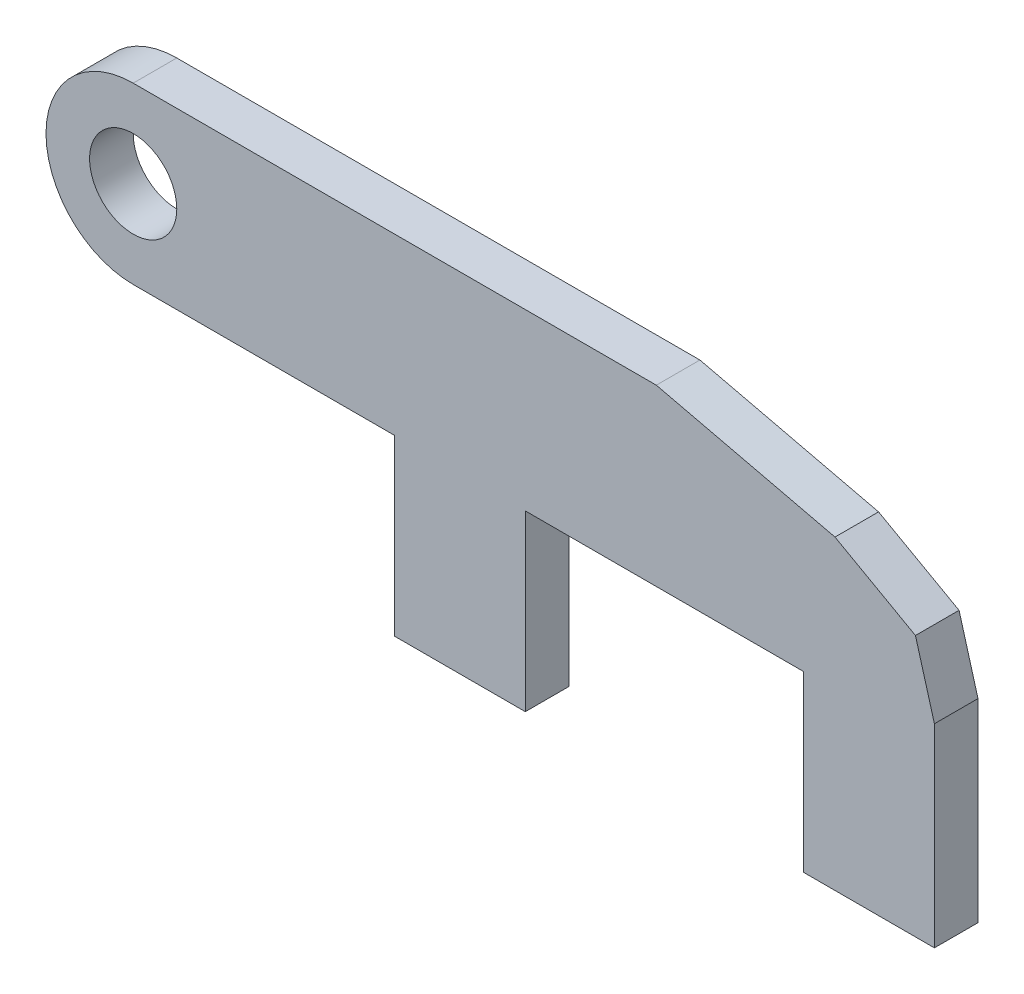
from build123d import *

# Parameters (mm, degrees)
SKETCH1_R           = 5
BOSS_EXTRUDE1_DEPTH = 5


with BuildPart() as part:
    # Sketch1 → Boss-Extrude1 (new body)
    with BuildSketch(Plane.XY):
        with BuildLine():
            Line((0, 20), (60, 20))
            Line((60, 20), (80.493425393, 15.160264355))
            Line((80.493425393, 15.160264355), (89.723935177, 10))
            Line((89.723935177, 10), (91.89696936, 2.317012659))
            Line((91.89696936, 2.317012659), (91.89696936, -19.946286041))
            Line((91.89696936, -19.946286041), (76.89696936, -19.946286041))
            Line((76.89696936, -19.946286041), (76.89696936, 0))
            Line((76.89696936, 0), (44.976259551, 0))
            Line((44.976259551, 0), (44.976259551, -19.946286041))
            Line((44.976259551, -19.946286041), (29.976259551, -19.946286041))
            Line((29.976259551, -19.946286041), (29.976259551, 0))
            Line((29.976259551, 0), (0, 0))
            ThreePointArc((0, 0), (-10, 10), (0, 20))
        make_face()
        with Locations((0, 10)):
            Circle(SKETCH1_R, mode=Mode.SUBTRACT)
    extrude(amount=BOSS_EXTRUDE1_DEPTH)


solid = part.part
